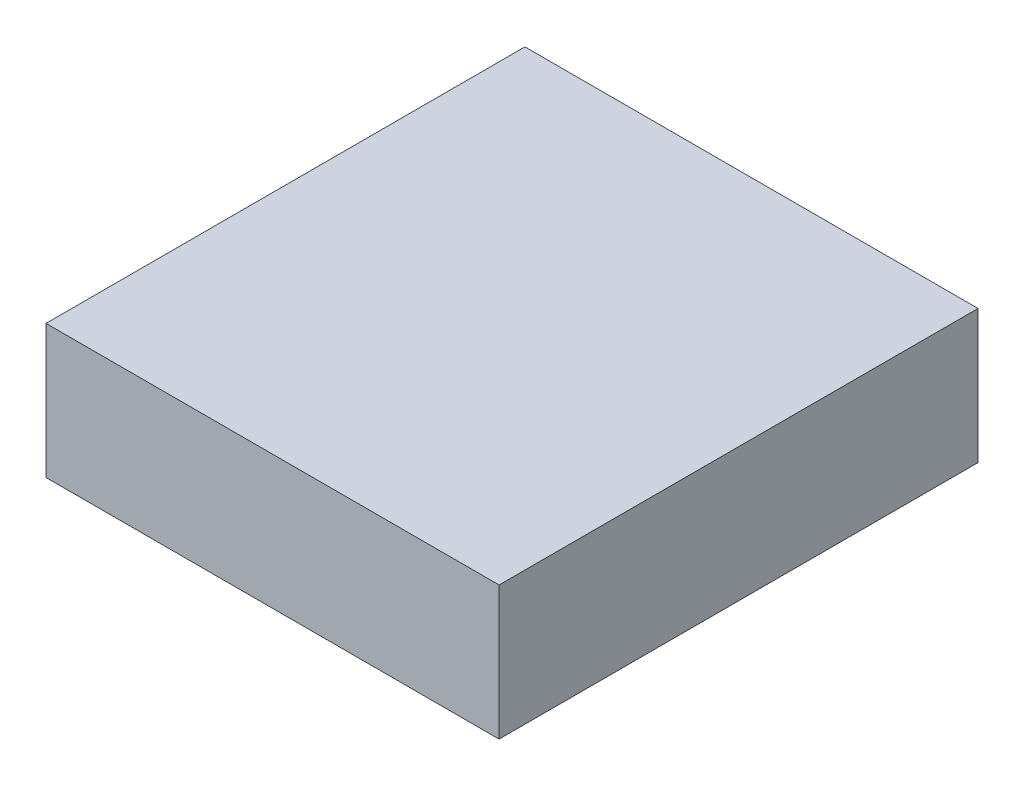
from build123d import *

# Parameters (mm, degrees)
SKETCH1_W           = 64
SKETCH1_H           = 67.65
BOSS_EXTRUDE1_DEPTH = 18.86


with BuildPart() as part:
    # Sketch1 → Boss-Extrude1 (new body)
    with BuildSketch(Plane(origin=(0, 0, 0), x_dir=(1, 0, 0), z_dir=(0, 1, 0))):
        with Locations((-32, 33.825)):
            Rectangle(SKETCH1_W, SKETCH1_H)
    extrude(amount=BOSS_EXTRUDE1_DEPTH)


solid = part.part
